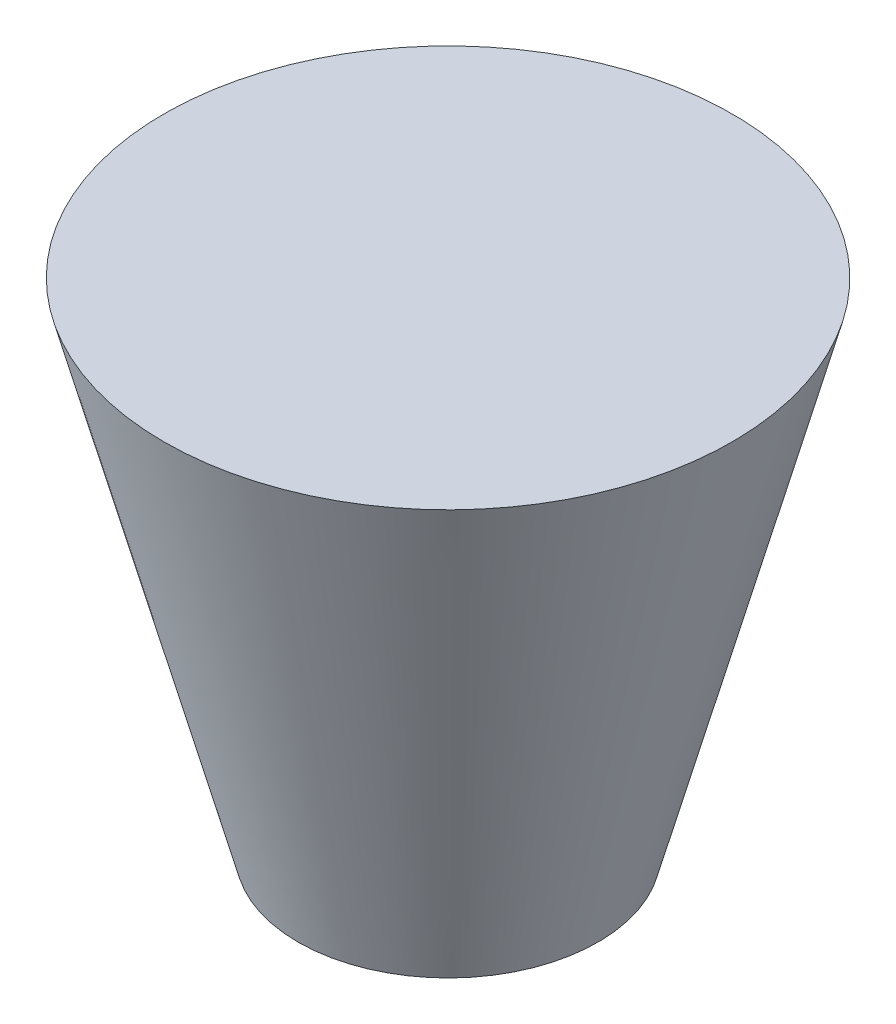
from build123d import *

# Parameters (mm, degrees)
SKETCH_1_R      = 150
EXTRUDE_1_DEPTH = 500
EXTRUDE_1_TAPER = -15


with BuildPart() as part:
    # 草图1 → 凸台-拉伸1 (new body)
    with BuildSketch(Plane(origin=(0, 0, 0), x_dir=(1, 0, 0), z_dir=(0, 1, 0))):
        with Locations((-23.503155964, 13.391333049)):
            Circle(SKETCH_1_R)
    extrude(amount=EXTRUDE_1_DEPTH, taper=EXTRUDE_1_TAPER)


solid = part.part
